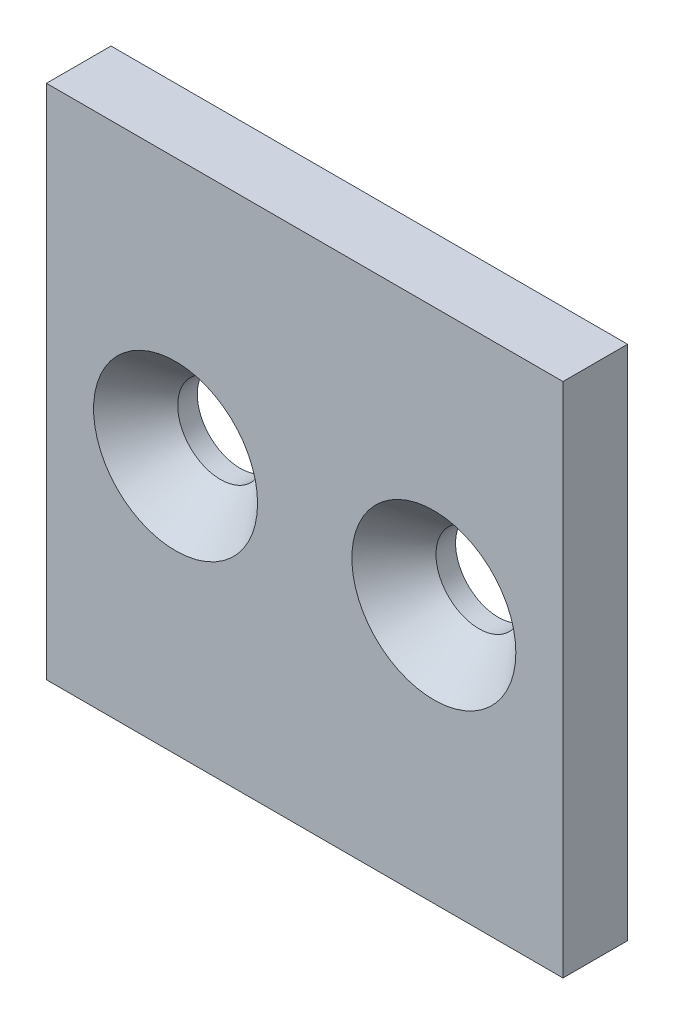
from build123d import *

# Parameters (mm, degrees)
SKETCH1_W                                         = 50.8
SKETCH1_H                                         = 50.8
SKETCH1_R                                         = 3.2639
BOSS_EXTRUDE1_DEPTH                               = 6.35
CSK_FOR_5_16_FLAT_HEAD_MACHINE_SCREW1_D           = 8.4328
CSK_FOR_5_16_FLAT_HEAD_MACHINE_SCREW1_DEPTH       = 32.766
CSK_FOR_5_16_FLAT_HEAD_MACHINE_SCREW1_CSINK_D     = 16.129
CSK_FOR_5_16_FLAT_HEAD_MACHINE_SCREW1_CSINK_ANGLE = 82
CSK_FOR_5_16_FLAT_HEAD_MACHINE_SCREW1_TIP         = 2.533468714


with BuildPart() as part:
    # Sketch1 → Boss-Extrude1 (new body)
    with BuildSketch(Plane.XY):
        Rectangle(SKETCH1_W, SKETCH1_H)
        with Locations((-12.7, 0)):
            Circle(SKETCH1_R, mode=Mode.SUBTRACT)
        with Locations((12.7, 0)):
            Circle(SKETCH1_R, mode=Mode.SUBTRACT)
    extrude(amount=-BOSS_EXTRUDE1_DEPTH)

    # CSK for 5/16 Flat Head Machine Screw1
    with Locations(Plane(origin=(-12.7, 0, 0), x_dir=(1, 0, 0), z_dir=(0, 0, 1))):
        with Locations((0, 0), (25.4, 0)):
            CounterSinkHole(CSK_FOR_5_16_FLAT_HEAD_MACHINE_SCREW1_D / 2, CSK_FOR_5_16_FLAT_HEAD_MACHINE_SCREW1_CSINK_D / 2, depth=CSK_FOR_5_16_FLAT_HEAD_MACHINE_SCREW1_DEPTH, counter_sink_angle=CSK_FOR_5_16_FLAT_HEAD_MACHINE_SCREW1_CSINK_ANGLE)
            with Locations((0, 0, -(CSK_FOR_5_16_FLAT_HEAD_MACHINE_SCREW1_DEPTH + CSK_FOR_5_16_FLAT_HEAD_MACHINE_SCREW1_TIP / 2))):  # 118° drill point
                Cone(0, CSK_FOR_5_16_FLAT_HEAD_MACHINE_SCREW1_D / 2, CSK_FOR_5_16_FLAT_HEAD_MACHINE_SCREW1_TIP, mode=Mode.SUBTRACT)


solid = part.part
